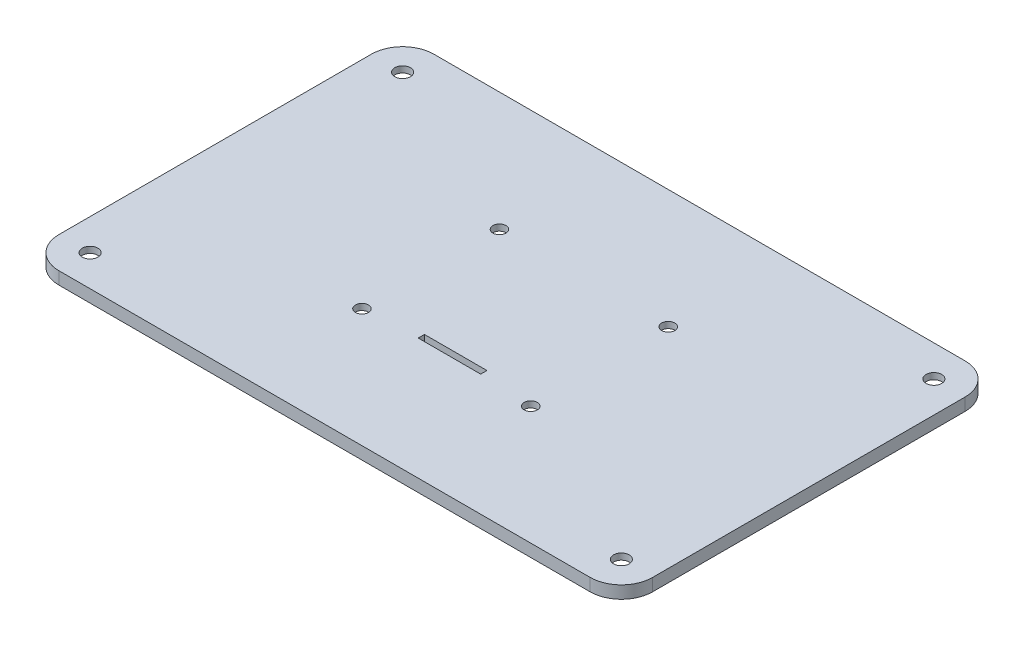
from build123d import *

# Parameters (mm, degrees)
SKETCH1_R                      = 5.5
BOSS_EXTRUDE1_DEPTH            = 5
BOSS_EXTRUDE2_DEPTH            = 2
SKETCH4_R                      = 1.4
BOSS_EXTRUDE3_DEPTH            = 7
SKETCH12_W                     = 20
SKETCH12_H                     = 2
CUT_EXTRUDE1_DEPTH             = 10
F_4_2_4_2_DIAMETER_HOLE1_D     = 4.2
F_4_2_4_2_DIAMETER_HOLE1_DEPTH = 20
F_4_2_4_2_DIAMETER_HOLE1_TIP   = 1.2618073
F_5_0_5_DIAMETER_HOLE1_D       = 5
F_5_0_5_DIAMETER_HOLE1_DEPTH   = 5
F_5_0_5_DIAMETER_HOLE1_TIP     = 1.502151548
SKETCH1_3_R                    = 5.5
CUT_EXTRUDE2_DEPTH             = 3


with BuildPart() as part:
    # Sketch1 → Boss-Extrude1 (new body)
    with BuildSketch(Plane(origin=(0, 111.722415865, 0), x_dir=(1, 0, 0), z_dir=(0, 1, 0))):
        with BuildLine():
            Line((241.95107426, 942.218289838), (411.95107426, 942.218289838))
            ThreePointArc((411.95107426, 942.218289838), (419.022142072, 945.147222026), (421.95107426, 952.218289838))
            Line((421.95107426, 952.218289838), (421.95107426, 1052.218289838))
            ThreePointArc((421.95107426, 1052.218289838), (419.022142072, 1059.28935765), (411.95107426, 1062.218289838))
            Line((411.95107426, 1062.218289838), (241.95107426, 1062.218289838))
            ThreePointArc((241.95107426, 1062.218289838), (234.880006448, 1059.28935765), (231.95107426, 1052.218289838))
            Line((231.95107426, 1052.218289838), (231.95107426, 952.218289838))
            ThreePointArc((231.95107426, 952.218289838), (234.880006448, 945.147222026), (241.95107426, 942.218289838))
        make_face()
        with Locations((241.95107426, 952.218289838)):
            Circle(SKETCH1_R, mode=Mode.SUBTRACT)
        with Locations((411.95107426, 952.218289838)):
            Circle(SKETCH1_R, mode=Mode.SUBTRACT)
        with Locations((411.95107426, 1052.218289838)):
            Circle(SKETCH1_R, mode=Mode.SUBTRACT)
        with Locations((241.95107426, 1052.218289838)):
            Circle(SKETCH1_R, mode=Mode.SUBTRACT)
        with BuildLine():
            Line((249.45107426, 952.218289838), (249.45107426, 944.718289838))
            Line((249.45107426, 944.718289838), (404.45107426, 944.718289838))
            Line((404.45107426, 944.718289838), (404.45107426, 952.218289838))
            ThreePointArc((404.45107426, 952.218289838), (406.647773401, 957.521590697), (411.95107426, 959.718289838))
            Line((411.95107426, 959.718289838), (419.45107426, 959.718289838))
            Line((419.45107426, 959.718289838), (419.45107426, 1044.718289838))
            Line((419.45107426, 1044.718289838), (411.95107426, 1044.718289838))
            ThreePointArc((411.95107426, 1044.718289838), (406.647773401, 1046.914988979), (404.45107426, 1052.218289838))
            Line((404.45107426, 1052.218289838), (404.45107426, 1059.718289838))
            Line((404.45107426, 1059.718289838), (249.45107426, 1059.718289838))
            Line((249.45107426, 1059.718289838), (249.45107426, 1052.218289838))
            ThreePointArc((249.45107426, 1052.218289838), (247.254375119, 1046.914988979), (241.95107426, 1044.718289838))
            Line((241.95107426, 1044.718289838), (234.45107426, 1044.718289838))
            Line((234.45107426, 1044.718289838), (234.45107426, 959.718289838))
            Line((234.45107426, 959.718289838), (241.95107426, 959.718289838))
            ThreePointArc((241.95107426, 959.718289838), (247.254375119, 957.521590697), (249.45107426, 952.218289838))
        make_face(mode=Mode.SUBTRACT)
    extrude(amount=BOSS_EXTRUDE1_DEPTH)

    # Sketch2 → Boss-Extrude2 (add)
    with BuildSketch(Plane(origin=(0, 116.722415865, 0), x_dir=(1, 0, 0), z_dir=(0, 1, 0))):
        with BuildLine():
            Line((231.95107426, 1052.218289838), (231.95107426, 952.218289838))
            ThreePointArc((231.95107426, 952.218289838), (234.880006448, 945.147222026), (241.95107426, 942.218289838))
            Line((241.95107426, 942.218289838), (411.95107426, 942.218289838))
            ThreePointArc((411.95107426, 942.218289838), (419.022142072, 945.147222026), (421.95107426, 952.218289838))
            Line((421.95107426, 952.218289838), (421.95107426, 1052.218289838))
            ThreePointArc((421.95107426, 1052.218289838), (419.022142072, 1059.28935765), (411.95107426, 1062.218289838))
            Line((411.95107426, 1062.218289838), (241.95107426, 1062.218289838))
            ThreePointArc((241.95107426, 1062.218289838), (234.880006448, 1059.28935765), (231.95107426, 1052.218289838))
        make_face()
    extrude(amount=BOSS_EXTRUDE2_DEPTH)

    # Sketch4 → Boss-Extrude3 (add)
    with BuildSketch(Plane(origin=(0, 118.722415865, 0), x_dir=(1, 0, 0), z_dir=(0, 1, 0))):
        with BuildLine():
            Line((375.86522753, 1030.272411662), (375.86522753, 1031.672411662))
            Line((375.86522753, 1031.672411662), (377.26522753, 1031.672411662))
            ThreePointArc((377.26522753, 1031.672411662), (374.875278036, 1032.662361156), (375.86522753, 1030.272411662))
        make_face()
        with BuildLine():
            Line((377.26522753, 1031.672411662), (375.86522753, 1031.672411662))
            Line((375.86522753, 1031.672411662), (375.86522753, 1030.272411662))
            ThreePointArc((375.86522753, 1030.272411662), (376.855177023, 1030.682462168), (377.26522753, 1031.672411662))
        make_face()
        with BuildLine():
            ThreePointArc((377.26522753, 1007.672411662), (376.855177023, 1008.662361156), (375.86522753, 1009.072411662))
            Line((375.86522753, 1009.072411662), (375.86522753, 1007.672411662))
            Line((375.86522753, 1007.672411662), (377.26522753, 1007.672411662))
        make_face()
        with BuildLine():
            Line((375.86522753, 1007.672411662), (375.86522753, 1009.072411662))
            ThreePointArc((375.86522753, 1009.072411662), (374.875278036, 1006.682462168), (377.26522753, 1007.672411662))
            Line((377.26522753, 1007.672411662), (375.86522753, 1007.672411662))
        make_face()
        with Locations((399.86522753, 1031.672411662)):
            Circle(SKETCH4_R)
        with Locations((399.86522753, 1007.672411662)):
            Circle(SKETCH4_R)
    extrude(amount=-BOSS_EXTRUDE3_DEPTH)

    # Sketch12 → Cut-Extrude1 (cut)
    with BuildSketch(Plane(origin=(0, 118.722415865, 0), x_dir=(1, 0, 0), z_dir=(0, 1, 0))):
        with Locations((328.108762335, 982.045276567)):
            Rectangle(SKETCH12_W, SKETCH12_H)
    extrude(amount=-CUT_EXTRUDE1_DEPTH, mode=Mode.SUBTRACT)

    # Ø4.2 (4.2) Diameter Hole1
    with Locations(Plane(origin=(0, 118.722415865, 0), x_dir=(1, 0, 0), z_dir=(0, 1, 0))):
        with Locations((300.990952506, 1024.17077451), (354.990952506, 1024.17077451), (354.990952506, 980.17077451), (300.990952506, 980.17077451)):
            Hole(F_4_2_4_2_DIAMETER_HOLE1_D / 2, depth=F_4_2_4_2_DIAMETER_HOLE1_DEPTH)
            with Locations((0, 0, -(F_4_2_4_2_DIAMETER_HOLE1_DEPTH + F_4_2_4_2_DIAMETER_HOLE1_TIP / 2))):  # 118° drill point
                Cone(0, F_4_2_4_2_DIAMETER_HOLE1_D / 2, F_4_2_4_2_DIAMETER_HOLE1_TIP, mode=Mode.SUBTRACT)

    # Ø5.0 (5) Diameter Hole1
    with Locations(Plane(origin=(0, 118.722415865, 0), x_dir=(1, 0, 0), z_dir=(0, 1, 0))):
        with Locations((241.95107426, 1052.218289838), (411.95107426, 1052.218289838), (411.95107426, 952.218289838), (241.95107426, 952.218289838)):
            Hole(F_5_0_5_DIAMETER_HOLE1_D / 2, depth=F_5_0_5_DIAMETER_HOLE1_DEPTH)
            with Locations((0, 0, -(F_5_0_5_DIAMETER_HOLE1_DEPTH + F_5_0_5_DIAMETER_HOLE1_TIP / 2))):  # 118° drill point
                Cone(0, F_5_0_5_DIAMETER_HOLE1_D / 2, F_5_0_5_DIAMETER_HOLE1_TIP, mode=Mode.SUBTRACT)

    # Sketch1_3 → Cut-Extrude2 (cut)
    with BuildSketch(Plane(origin=(0, 111.722415865, 0), x_dir=(1, 0, 0), z_dir=(0, 1, 0))):
        with BuildLine():
            Line((241.95107426, 942.218289838), (411.95107426, 942.218289838))
            ThreePointArc((411.95107426, 942.218289838), (419.022142072, 945.147222026), (421.95107426, 952.218289838))
            Line((421.95107426, 952.218289838), (421.95107426, 1052.218289838))
            ThreePointArc((421.95107426, 1052.218289838), (419.022142072, 1059.28935765), (411.95107426, 1062.218289838))
            Line((411.95107426, 1062.218289838), (241.95107426, 1062.218289838))
            ThreePointArc((241.95107426, 1062.218289838), (234.880006448, 1059.28935765), (231.95107426, 1052.218289838))
            Line((231.95107426, 1052.218289838), (231.95107426, 952.218289838))
            ThreePointArc((231.95107426, 952.218289838), (234.880006448, 945.147222026), (241.95107426, 942.218289838))
        make_face()
        with Locations((241.95107426, 952.218289838)):
            Circle(SKETCH1_3_R, mode=Mode.SUBTRACT)
        with Locations((411.95107426, 952.218289838)):
            Circle(SKETCH1_3_R, mode=Mode.SUBTRACT)
        with Locations((411.95107426, 1052.218289838)):
            Circle(SKETCH1_3_R, mode=Mode.SUBTRACT)
        with Locations((241.95107426, 1052.218289838)):
            Circle(SKETCH1_3_R, mode=Mode.SUBTRACT)
        with BuildLine():
            Line((249.45107426, 952.218289838), (249.45107426, 944.718289838))
            Line((249.45107426, 944.718289838), (404.45107426, 944.718289838))
            Line((404.45107426, 944.718289838), (404.45107426, 952.218289838))
            ThreePointArc((404.45107426, 952.218289838), (406.647773401, 957.521590697), (411.95107426, 959.718289838))
            Line((411.95107426, 959.718289838), (419.45107426, 959.718289838))
            Line((419.45107426, 959.718289838), (419.45107426, 1044.718289838))
            Line((419.45107426, 1044.718289838), (411.95107426, 1044.718289838))
            ThreePointArc((411.95107426, 1044.718289838), (406.647773401, 1046.914988979), (404.45107426, 1052.218289838))
            Line((404.45107426, 1052.218289838), (404.45107426, 1059.718289838))
            Line((404.45107426, 1059.718289838), (249.45107426, 1059.718289838))
            Line((249.45107426, 1059.718289838), (249.45107426, 1052.218289838))
            ThreePointArc((249.45107426, 1052.218289838), (247.254375119, 1046.914988979), (241.95107426, 1044.718289838))
            Line((241.95107426, 1044.718289838), (234.45107426, 1044.718289838))
            Line((234.45107426, 1044.718289838), (234.45107426, 959.718289838))
            Line((234.45107426, 959.718289838), (241.95107426, 959.718289838))
            ThreePointArc((241.95107426, 959.718289838), (247.254375119, 957.521590697), (249.45107426, 952.218289838))
        make_face(mode=Mode.SUBTRACT)
    extrude(amount=CUT_EXTRUDE2_DEPTH, mode=Mode.SUBTRACT)


solid = part.part
